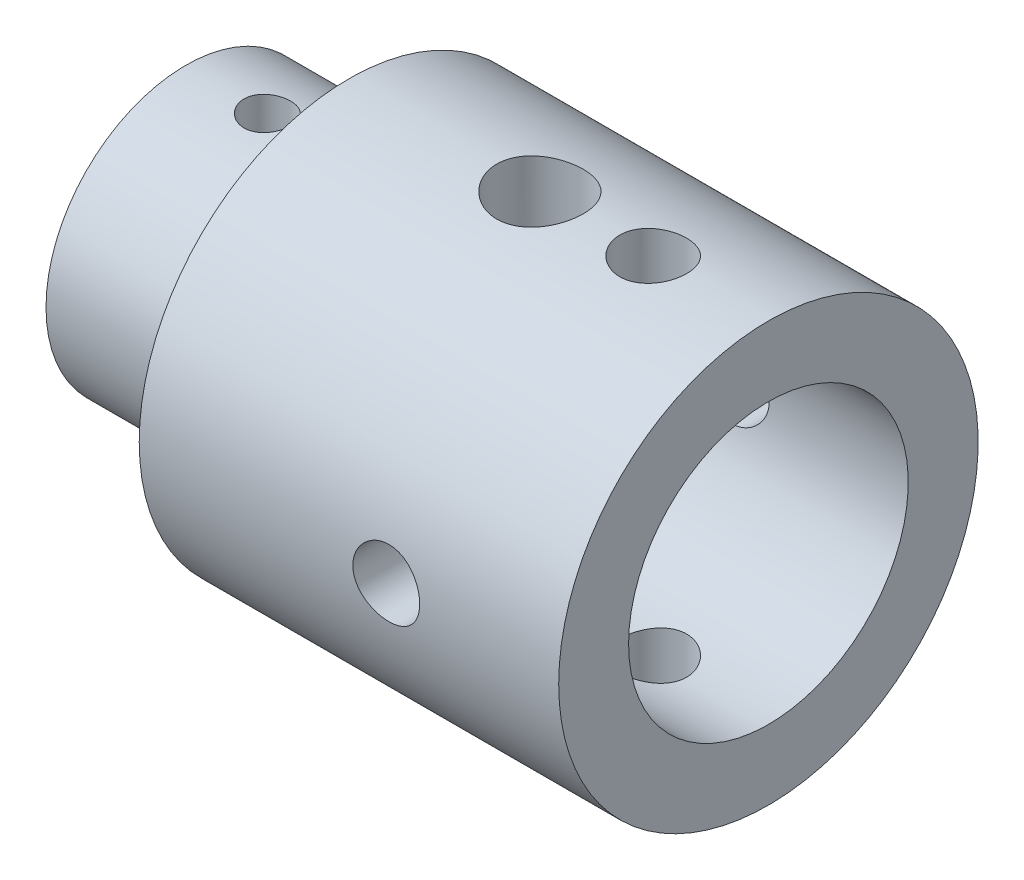
from build123d import *

# Parameters (mm, degrees)
CORTAR_EXTRUIR1_DEPTH      = 7
CROQUIS3_R                 = 1
CORTAR_EXTRUIR2_DEPTH      = 7
CROQUIS4_R                 = 1.855
CROQUIS4_R_2               = 1.435
CORTAR_EXTRUIR3_DEPTH      = 28
CROQUIS5_R                 = 1.435
CORTAR_EXTRUIR4_DEPTH      = 10.0000001
CORTAR_EXTRUIR4_DEPTH_BACK = 10.0000001


with BuildPart() as part:
    # Croquis1 → Revolución1 (revolve)
    with BuildSketch(Plane(origin=(0, 0, 0), x_dir=(1, 0, 0), z_dir=(0, 1, 0))):
        Polygon((10, 0), (10, 6), (25, 6), (25, 9), (7, 9), (7, 6), (0, 6), (0, 0), align=None)
    revolve(axis=Axis((-57.080066138, 0, 0), (1, 0, 0)))

    # Croquis2 → Cortar-Extruir1 (cut)
    with BuildSketch(Plane.ZY):
        with BuildLine():
            Line((-1, 1.5), (1, 1.5))
            ThreePointArc((1, 1.5), (2.5, 0), (1, -1.5))
            Line((1, -1.5), (-1, -1.5))
            ThreePointArc((-1, -1.5), (-2.5, 0), (-1, 1.5))
        make_face()
    extrude(amount=-CORTAR_EXTRUIR1_DEPTH, mode=Mode.SUBTRACT)

    # Croquis3 → Cortar-Extruir2 (cut, symmetric)
    with BuildSketch(Plane(origin=(0, 0, 0), x_dir=(1, 0, 0), z_dir=(0, 1, 0))):
        with Locations((3.5, 0)):
            Circle(CROQUIS3_R)
    extrude(amount=CORTAR_EXTRUIR2_DEPTH, both=True, mode=Mode.SUBTRACT)

    # Croquis4 → Cortar-Extruir3 (cut)
    with BuildSketch(Plane(origin=(0, -9, 0), x_dir=(-1, 0, 0), z_dir=(0, -1, 0))):
        with Locations((-15.195, 0)):
            Circle(CROQUIS4_R)
        with Locations((-20.055, 0)):
            Circle(CROQUIS4_R_2)
    extrude(amount=-CORTAR_EXTRUIR3_DEPTH, mode=Mode.SUBTRACT)

    # Croquis5 → Cortar-Extruir4 (cut, two sides)
    with BuildSketch(Plane.XY) as cortar_extruir4_sk:
        with Locations((17.6, 0)):
            Circle(CROQUIS5_R)
    extrude(amount=CORTAR_EXTRUIR4_DEPTH, mode=Mode.SUBTRACT)
    extrude(cortar_extruir4_sk.sketch, amount=-CORTAR_EXTRUIR4_DEPTH_BACK, mode=Mode.SUBTRACT)


solid = part.part
